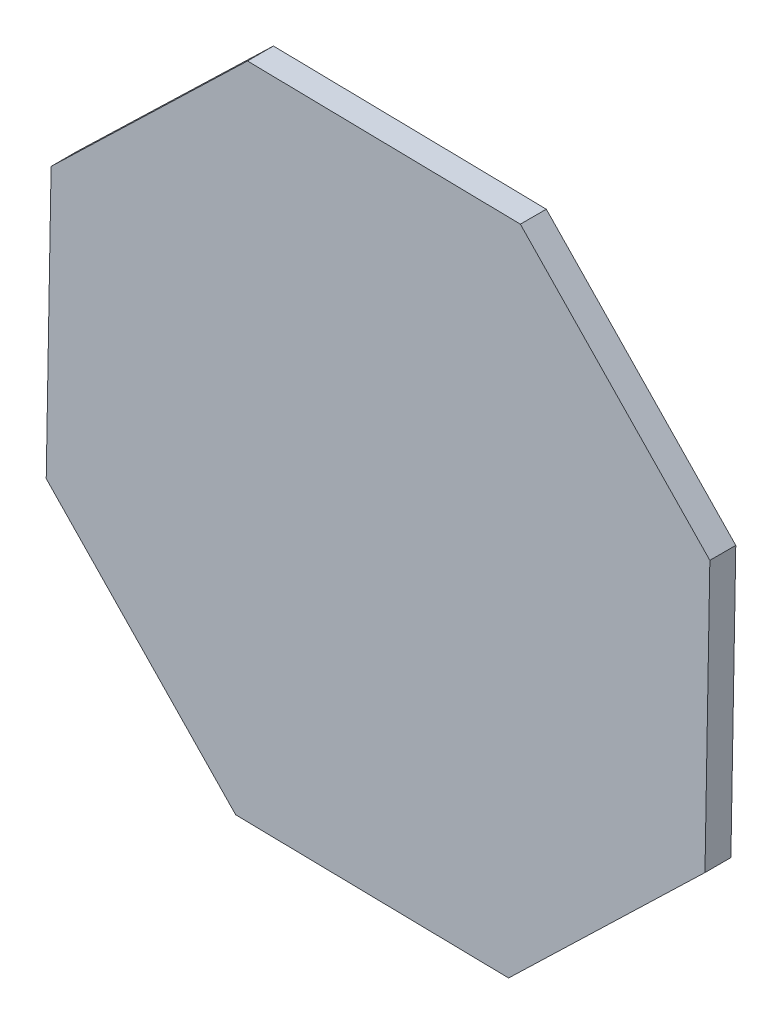
from build123d import *

# Parameters (mm, degrees)
BOSS_EXTRUDE1_DEPTH = 5.08


with BuildPart() as part:
    # Sketch1 → Boss-Extrude1 (new body, symmetric)
    with BuildSketch(Plane.XY):
        Polygon((-130.002732772, -51.140780907), (-55.763820942, -128.08780689), (51.140780907, -130.002732772), (128.08780689, -55.763820942), (130.002732772, 51.140780907), (55.763820942, 128.08780689), (-51.140780907, 130.002732772), (-128.08780689, 55.763820942), align=None)
    extrude(amount=BOSS_EXTRUDE1_DEPTH, both=True)


solid = part.part
